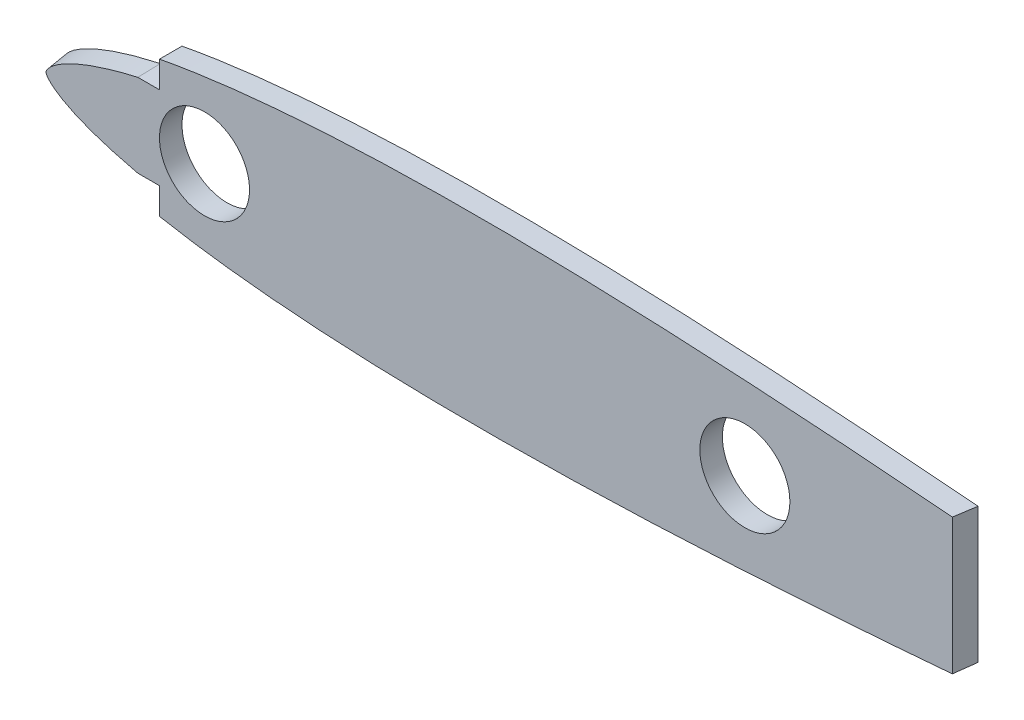
from build123d import *

# Parameters (mm, degrees)
BOSS_EXTRUDE1_DEPTH     = 3.175
SKETCH2_R               = 6.35
CUT_EXTRUDE1_DEPTH      = 4.1750001
CUT_EXTRUDE2_DEPTH      = 13.851031146
CUT_EXTRUDE2_DEPTH_BACK = 13.851031146


with BuildPart() as part:
    # Sketch1 → Boss-Extrude1 (new body)
    with BuildSketch(Plane.XY):
        with BuildLine():
            add(Edge.make_bspline(
                [(214.122, 0.26979372), (214.042517561, 0.336401081), (213.528971009, 0.273510814), (212.614475706, 0.530942112), (210.937412976, 0.69005818), (208.678154781, 1.031540783), (205.767891794, 1.412612557), (202.258298365, 1.882266), (198.158505405, 2.4131646), (193.498201346, 3.004251359), (188.3046229, 3.645171414), (182.610259265, 4.327250831), (176.450111776, 5.042029836), (169.862114854, 5.779776892), (162.886908752, 6.531484704), (155.567547263, 7.287816965), (147.949138879, 8.039011284), (140.078674392, 8.774523149), (132.004623532, 9.484696808), (123.776853773, 10.157659428), (115.445921162, 10.782438327), (107.063264355, 11.347433986), (98.680532246, 11.840832833), (90.349330839, 12.250169768), (82.121113367, 12.564529441), (74.046372156, 12.77365626), (66.175007458, 12.867335678), (58.555385553, 12.838133258), (51.234483397, 12.680408315), (44.257364483, 12.390162696), (37.666974317, 11.966637162), (31.503817676, 11.411106073), (25.805608692, 10.727908153), (20.607079774, 9.922856403), (15.939732749, 9.004358901), (11.830923582, 7.982801344), (8.304000309, 6.868145192), (5.376882013, 5.670771919), (3.058903356, 4.398782317), (1.353631156, 3.049665872), (0.261418186, 1.590784391), (-0.121830169, 0), (0.261418186, -1.590784391), (1.353631156, -3.049665872), (3.058903356, -4.398782317), (5.376882013, -5.670771919), (8.304000309, -6.868145192), (11.830923582, -7.982801344), (15.939732749, -9.004358901), (20.607079774, -9.922856403), (25.805608692, -10.727908153), (31.503817676, -11.411106073), (37.666974317, -11.966637162), (44.257364483, -12.390162696), (51.234483397, -12.680408315), (58.555385553, -12.838133258), (66.175007458, -12.867335678), (74.046372156, -12.77365626), (82.121113367, -12.564529441), (90.349330839, -12.250169768), (98.680532246, -11.840832833), (107.063264355, -11.347433986), (115.445921162, -10.782438327), (123.776853773, -10.157659428), (132.004623532, -9.484696808), (140.078674392, -8.774523149), (147.949138879, -8.039011284), (155.567547263, -7.287816965), (162.886908752, -6.531484704), (169.862114854, -5.779776892), (176.450111776, -5.042029836), (182.610259265, -4.327250831), (188.3046229, -3.645171414), (193.498201346, -3.004251359), (198.158505405, -2.4131646), (202.258298365, -1.882266), (205.767891794, -1.412612557), (208.678154781, -1.031540783), (210.937412976, -0.69005818), (212.614475706, -0.530942112), (213.528971009, -0.273510814), (214.25071943, -0.361898032), (214.25071943, 0.161925093), (214.122, 0.26979372)],
                knots=[0, 0, 0, 0, 0.000762215, 0.003044706, 0.006832246, 0.012101176, 0.018817536, 0.026939455, 0.036414848, 0.047184629, 0.059180413, 0.072327874, 0.086544061, 0.10174058, 0.117823336, 0.134691452, 0.152240154, 0.17036129, 0.188941008, 0.207865435, 0.227016078, 0.246275696, 0.265524943, 0.284644966, 0.303520118, 0.322034575, 0.340078353, 0.357542593, 0.374325482, 0.390329891, 0.40546389, 0.419643801, 0.432793371, 0.444843817, 0.455737921, 0.465428653, 0.47388632, 0.481101634, 0.487101684, 0.491975368, 0.495930678, 0.499382808, 0.502834938, 0.506790248, 0.511663932, 0.517663982, 0.524879296, 0.533336963, 0.543027695, 0.553921799, 0.565972245, 0.579121815, 0.593301726, 0.608435725, 0.624440134, 0.641223023, 0.658687263, 0.676731041, 0.695245498, 0.71412065, 0.733240673, 0.75248992, 0.771749538, 0.790900181, 0.809824608, 0.828404326, 0.846525462, 0.864074164, 0.88094228, 0.897025036, 0.912221555, 0.926437743, 0.939585203, 0.951580988, 0.962350768, 0.971826161, 0.979948081, 0.98666444, 0.991933371, 0.99572091, 0.998003402, 0.998765616, 1, 1, 1, 1], degree=3))
        make_face()
    extrude(amount=BOSS_EXTRUDE1_DEPTH)

    # Sketch2 → Cut-Extrude1 (cut, through all)
    with BuildSketch(Plane.XY.offset(3.175)):
        with Locations((25.4, 0)):
            Circle(SKETCH2_R)
        with Locations((101.6, 0)):
            Circle(SKETCH2_R)
    extrude(amount=-CUT_EXTRUDE1_DEPTH, mode=Mode.SUBTRACT)

    # Sketch4 → Cut-Extrude2 (cut, two sides)
    with BuildSketch(Plane(origin=(0, 0, 0), x_dir=(1, 0, 0), z_dir=(0, 1, 0))) as cut_extrude2_sk:
        Polygon((131.301372669, 0), (130.854723983, -3.175), (214.218539573, -3.175), (214.218539573, 0), align=None)
    extrude(amount=CUT_EXTRUDE2_DEPTH, mode=Mode.SUBTRACT)
    extrude(cut_extrude2_sk.sketch, amount=-CUT_EXTRUDE2_DEPTH_BACK, mode=Mode.SUBTRACT)

    # Sketch6 → Cut-Loft1 section 0
    with BuildSketch(Plane.XY.offset(3.175)):
        with BuildLine():
            Line((19.05, -5.856388973), (19.05, -9.60451625))
            Line((19.05, -9.60451625), (19.05, -13.496705478))
            Line((19.05, -13.496705478), (-3.17679028, -18.7418168))
            Line((-3.17679028, -18.7418168), (-7.400210772, 8.670878009))
            Line((-7.400210772, 8.670878009), (19.05, 13.499844305))
            Line((19.05, 13.499844305), (19.05, 9.60451625))
            Line((19.05, 9.60451625), (19.05, 5.856388972))
            Line((19.05, 5.856388972), (16.002, 5.855689085))
            add(Edge.make_bspline(
                [(16.002, 5.855689085), (15.278985699, 5.689672728), (14.191834186, 5.424851558), (12.757843363, 5.037907465), (11.69367278, 4.729775055), (10.646700316, 4.403337894), (9.617692504, 4.055796047), (8.608301637, 3.684577658), (7.626216232, 3.28790719), (6.678573411, 2.8637313), (5.779182107, 2.40890834), (5.078910801, 2.000461241), (4.5709467, 1.665455737), (4.220151013, 1.411514439), (3.905914023, 1.157647081), (3.631157505, 0.904651906), (3.399885574, 0.653944439), (3.226743451, 0.433066972), (3.126676284, 0.2697322), (3.07552602, 0.144421915), (3.049218429, 0.037663177), (3.047390298, 5.5e-08), (3.04921854, -0.03766331), (3.075525744, -0.1444217), (3.126676947, -0.269732641), (3.226742145, -0.433066135), (3.399888053, -0.653946015), (3.631152817, -0.904648933), (3.905923107, -1.157652839), (4.220131475, -1.411502059), (4.570981553, -1.665477812), (5.078773369, -2.000374258), (5.77925724, -2.408956031), (6.678536824, -2.863707828), (7.626233895, -3.287919031), (8.608295197, -3.684572243), (9.617690306, -4.05579733), (10.64671253, -4.403340225), (11.693641898, -4.729767367), (12.757897505, -5.037921267), (14.191640812, -5.424801637), (15.278985699, -5.689672728), (16.002, -5.855689085)],
                knots=[0, 0, 0, 0, 0.0625, 0.09375, 0.125, 0.15625, 0.1875, 0.21875, 0.25, 0.28125, 0.3125, 0.34375, 0.359375, 0.375, 0.390625, 0.40625, 0.421875, 0.4375, 0.453125, 0.46875, 0.484375, 0.5, 0.515625, 0.53125, 0.546875, 0.5625, 0.578125, 0.59375, 0.609375, 0.625, 0.640625, 0.65625, 0.6875, 0.71875, 0.75, 0.78125, 0.8125, 0.84375, 0.875, 0.90625, 0.9375, 1, 1, 1, 1], degree=3))
            Line((16.002, -5.855689085), (19.05, -5.856388973))
        make_face()
    # Sketch5 → Cut-Loft1 section 1
    with BuildSketch(Plane(origin=(0, 0, 0), x_dir=(-1, 0, 0), z_dir=(0, 0, -1))):
        with BuildLine():
            Line((-19.05, -9.69489598), (-19.05, -5.952242124))
            Line((-19.05, -5.952242124), (-16.002, -5.952242124))
            add(Edge.make_bspline(
                [(-16.002, 5.952242124), (-15.254770655, 5.78657596), (-14.131320952, 5.521981031), (-12.64893123, 5.134599211), (-11.548436123, 4.825723352), (-10.465051878, 4.498073941), (-9.399590771, 4.148800211), (-8.353696965, 3.775270971), (-7.504851445, 3.442218555), (-6.842934482, 3.161623807), (-6.194794877, 2.871042337), (-5.414728041, 2.488039147), (-4.683877816, 2.074629942), (-4.151373193, 1.734752799), (-3.782164679, 1.476616997), (-3.449549124, 1.21792525), (-3.156545696, 0.959314296), (-2.90735717, 0.702084345), (-2.716911913, 0.473376027), (-2.620007494, 0.329250424), (-2.568278365, 0.232230216), (-2.539730887, 0.166366119), (-2.518563335, 0.105023254), (-2.505407276, 0.055343345), (-2.499698937, 0.022962059), (-2.498722808, 3.7e-08), (-2.499699014, -0.022962102), (-2.505407277, -0.055343359), (-2.518563346, -0.105023288), (-2.539730598, -0.166365891), (-2.568278462, -0.232230258), (-2.620012631, -0.329254292), (-2.716907842, -0.47337309), (-2.907361053, -0.702086989), (-3.156540251, -0.959310743), (-3.449558648, -1.217931354), (-3.782145051, -1.476604524), (-4.151407833, -1.734774759), (-4.683741695, -2.074543768), (-5.414804155, -2.48808676), (-6.194777113, -2.871030834), (-6.84292503, -3.16161805), (-7.50486635, -3.442227642), (-8.353689563, -3.77526546), (-9.399589141, -4.148801556), (-10.465063669, -4.498076208), (-11.54840573, -4.825715767), (-12.648984703, -5.134612855), (-14.131129756, -5.52193166), (-15.254770655, -5.78657596), (-16.002, -5.952242124)],
                knots=[0, 0, 0, 0, 0.0625, 0.09375, 0.125, 0.15625, 0.1875, 0.21875, 0.25, 0.265625, 0.28125, 0.3125, 0.34375, 0.359375, 0.375, 0.390625, 0.40625, 0.421875, 0.4375, 0.453125, 0.4609375, 0.46875, 0.4765625, 0.484375, 0.4921875, 0.5, 0.5078125, 0.515625, 0.5234375, 0.53125, 0.5390625, 0.546875, 0.5625, 0.578125, 0.59375, 0.609375, 0.625, 0.640625, 0.65625, 0.6875, 0.71875, 0.734375, 0.75, 0.78125, 0.8125, 0.84375, 0.875, 0.90625, 0.9375, 1, 1, 1, 1], degree=3))
            Line((-16.002, 5.952242124), (-19.05, 5.952242124))
            Line((-19.05, 5.952242124), (-19.05, 9.69489598))
            Line((-19.05, 9.69489598), (-19.05, 12.377646409))
            Line((-19.05, 12.377646409), (3.93721866, 8.635694366))
            Line((3.93721866, 8.635694366), (2.51171312, -11.744580154))
            Line((2.51171312, -11.744580154), (-19.05, -12.301418255))
            Line((-19.05, -12.301418255), (-19.05, -9.69489598))
        make_face()
    loft(mode=Mode.SUBTRACT)


solid = part.part
